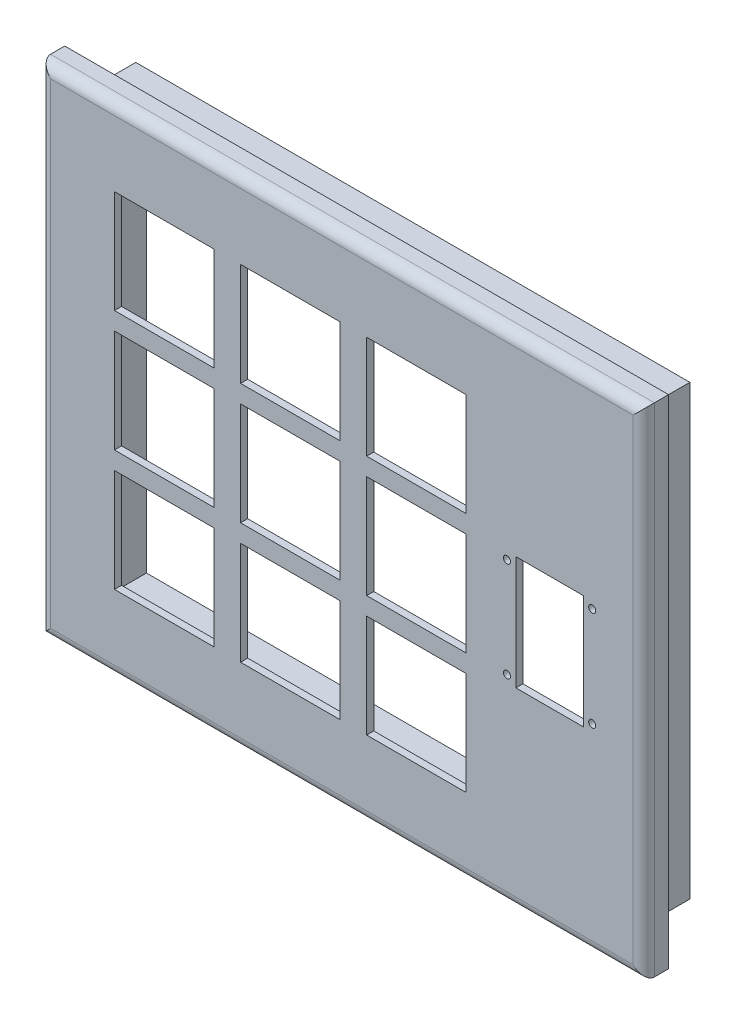
from build123d import *

# Parameters (mm, degrees)
CROQUIS1_W              = 170
CROQUIS1_H              = 140
SALIENTE_EXTRUIR1_DEPTH = 20
CROQUIS2_W              = 170
CROQUIS2_H              = 140
CROQUIS2_W_2            = 156
CROQUIS2_H_2            = 126
CORTAR_EXTRUIR1_DEPTH   = 13
CROQUIS3_W              = 150
CROQUIS3_H              = 120
CORTAR_EXTRUIR2_DEPTH   = 18
CROQUIS4_R              = 1
CROQUIS4_W              = 28
CROQUIS4_H              = 29
CROQUIS4_W_2            = 19
CROQUIS4_H_2            = 32
CORTAR_EXTRUIR3_DEPTH   = 18
REDONDEO1_R             = 3


with BuildPart() as part:
    # Croquis1 → Saliente-Extruir1 (new body)
    with BuildSketch(Plane.XY):
        Rectangle(CROQUIS1_W, CROQUIS1_H)
    extrude(amount=SALIENTE_EXTRUIR1_DEPTH)

    # Croquis2 → Cortar-Extruir1 (cut)
    with BuildSketch(Plane(origin=(0, 0, 0), x_dir=(-1, 0, 0), z_dir=(0, 0, -1))):
        Rectangle(CROQUIS2_W, CROQUIS2_H)
        Rectangle(CROQUIS2_W_2, CROQUIS2_H_2, mode=Mode.SUBTRACT)
    extrude(amount=-CORTAR_EXTRUIR1_DEPTH, mode=Mode.SUBTRACT)

    # Croquis3 → Cortar-Extruir2 (cut)
    with BuildSketch(Plane(origin=(0, 0, 0), x_dir=(-1, 0, 0), z_dir=(0, 0, -1))):
        Rectangle(CROQUIS3_W, CROQUIS3_H)
    extrude(amount=-CORTAR_EXTRUIR2_DEPTH, mode=Mode.SUBTRACT)

    # Croquis4 → Cortar-Extruir3 (cut)
    with BuildSketch(Plane(origin=(0, 0, 18), x_dir=(-1, 0, 0), z_dir=(0, 0, -1))):
        with Locations((-46.5, -14)):
            Circle(CROQUIS4_R)
        with Locations((-46.5, 14)):
            Circle(CROQUIS4_R)
        with Locations((-70.5, -14)):
            Circle(CROQUIS4_R)
        with Locations((-70.5, 14)):
            Circle(CROQUIS4_R)
        with Locations((50, -34)):
            Rectangle(CROQUIS4_W, CROQUIS4_H)
        with Locations((50, 0)):
            Rectangle(CROQUIS4_W, CROQUIS4_H)
        with Locations((50, 34)):
            Rectangle(CROQUIS4_W, CROQUIS4_H)
        with Locations((14.5, 0)):
            Rectangle(CROQUIS4_W, CROQUIS4_H)
        with Locations((14.5, -34)):
            Rectangle(CROQUIS4_W, CROQUIS4_H)
        with Locations((-21, -34)):
            Rectangle(CROQUIS4_W, CROQUIS4_H)
        with Locations((14.5, 34)):
            Rectangle(CROQUIS4_W, CROQUIS4_H)
        with Locations((-21, 0)):
            Rectangle(CROQUIS4_W, CROQUIS4_H)
        with Locations((-21, 34)):
            Rectangle(CROQUIS4_W, CROQUIS4_H)
        with Locations((-58.5, 0)):
            Rectangle(CROQUIS4_W_2, CROQUIS4_H_2)
    extrude(amount=-CORTAR_EXTRUIR3_DEPTH, mode=Mode.SUBTRACT)

    # Redondeo1
    redondeo1_edges = [part.edges().sort_by_distance(p)[0] for p in [
        (-85, 0, 20),
        (0, -70, 20),
        (85, 0, 20),
        (0, 70, 20),
    ]]
    fillet(redondeo1_edges, radius=REDONDEO1_R)


solid = part.part
